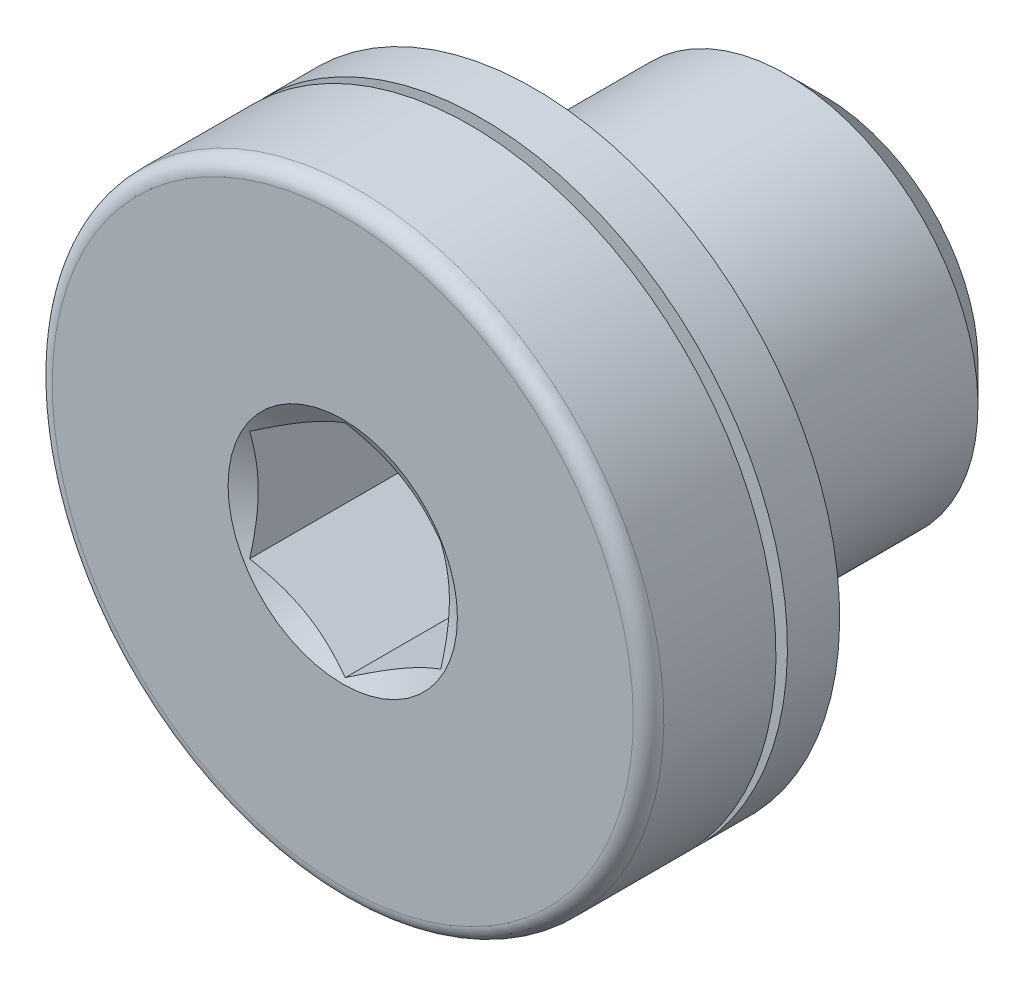
from build123d import *

# Parameters (mm, degrees)
CUT_EXTRUDE1_DEPTH = 2.5


with BuildPart() as part:
    # Sketch1 → Revolve1 (revolve)
    with BuildSketch(Plane(origin=(0, 0, 0), x_dir=(0, 0, -1), z_dir=(1, 0, 0))):
        with BuildLine():
            Line((-1.633974596, 0), (-2.5, 1.5))
            Line((-2.5, 1.5), (-2.5, 3.8))
            ThreePointArc((-2.5, 3.8), (-2.441421356, 3.941421356), (-2.3, 4))
            Line((-2.3, 4), (-0.833333333, 4))
            Line((-0.833333333, 4), (-0.833333333, 3.6))
            Line((-0.833333333, 3.6), (-0.683333333, 3.6))
            Line((-0.683333333, 3.6), (-0.683333333, 4))
            Line((-0.683333333, 4), (0, 4))
            Line((0, 4), (0, 2.0095))
            Line((0, 2.0095), (0.4905, 2.5))
            Line((0.4905, 2.5), (3.3095, 2.5))
            Line((3.3095, 2.5), (3.8, 2.0095))
            Line((3.8, 2.0095), (3.8, 0))
            Line((3.8, 0), (-1.633974596, 0))
        make_face()
    revolve(axis=Axis((0, 0, -3.8), (0, 0, 1)))

    # Sketch2 → Cut-Extrude1 (cut)
    with BuildSketch(Plane.XY.offset(2.5)):
        Polygon((-1.25, -0.721687836), (0, -1.443375673), (1.25, -0.721687836), (1.25, 0.721687836), (0, 1.443375673), (-1.25, 0.721687836), align=None)
    extrude(amount=-CUT_EXTRUDE1_DEPTH, mode=Mode.SUBTRACT)


solid = part.part
